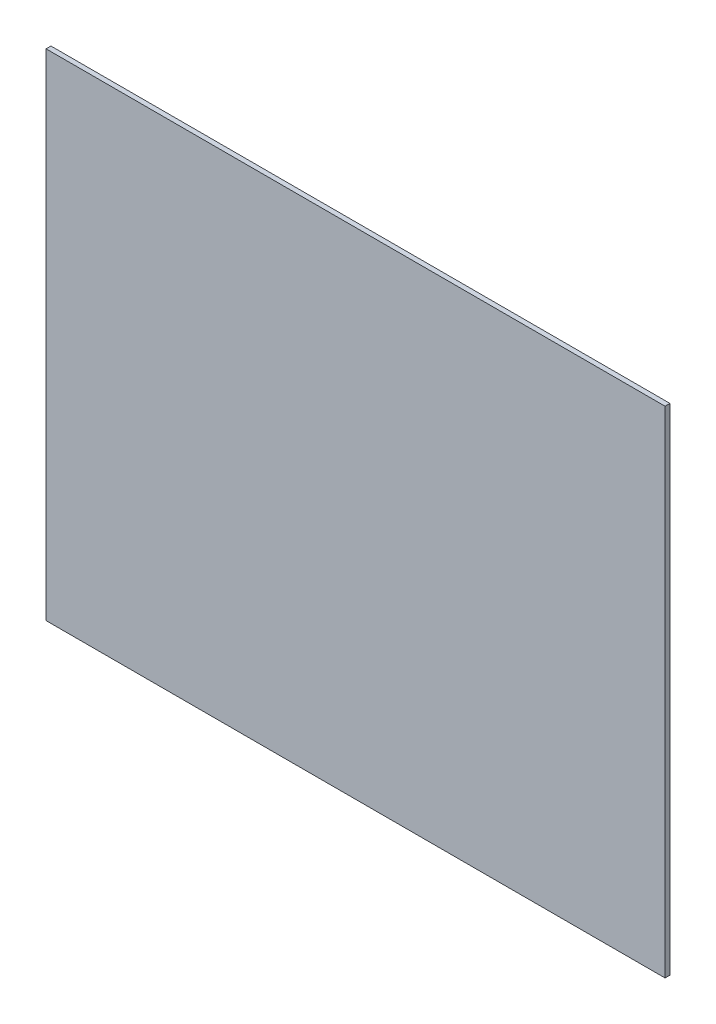
from build123d import *

# Parameters (mm, degrees)
SKETCH1_W           = 190.5
SKETCH1_H           = 152.4
BOSS_EXTRUDE1_DEPTH = 1.5


with BuildPart() as part:
    # Sketch1 → Boss-Extrude1 (new body)
    with BuildSketch(Plane.XY):
        Rectangle(SKETCH1_W, SKETCH1_H)
    extrude(amount=BOSS_EXTRUDE1_DEPTH)


solid = part.part
